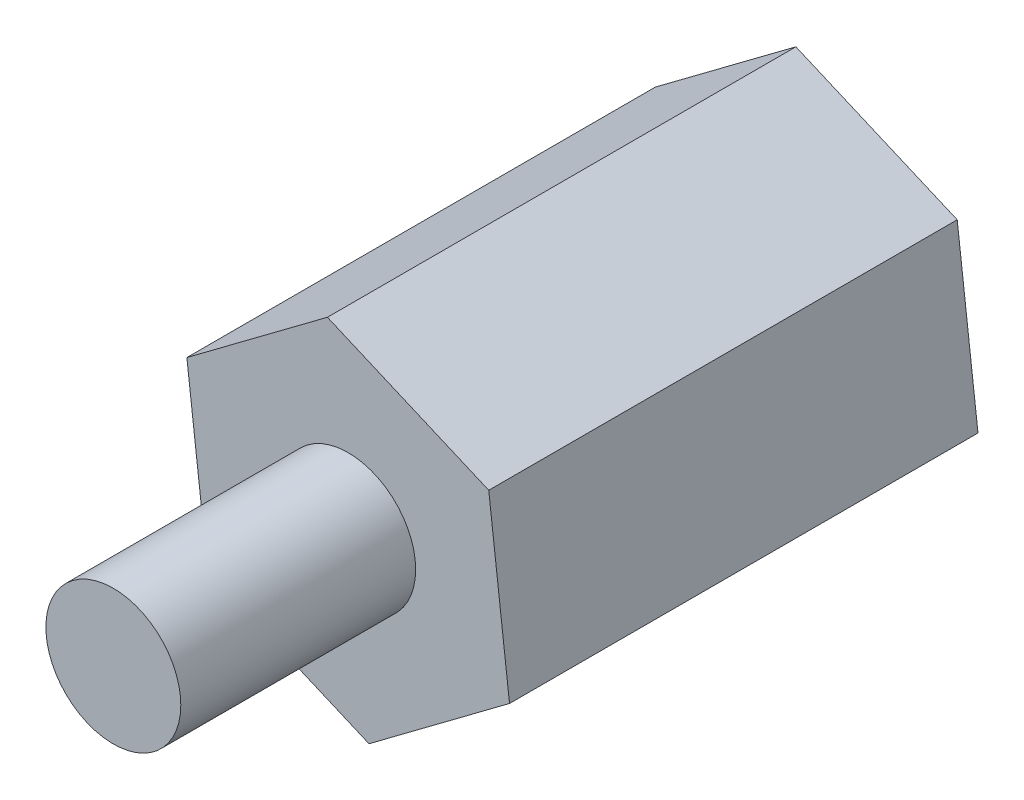
from build123d import *

# Parameters (mm, degrees)
SKETCH7_R           = 1.3716
BOSS_EXTRUDE4_DEPTH = 4.7625
SKETCH8_R           = 1.3716
BOSS_EXTRUDE5_DEPTH = 4.7752


with BuildPart() as part:
    # Sketch7 → Boss-Extrude4 (new, symmetric)
    with BuildSketch(Plane.XY):
        Polygon((-76.439762625, 4.738534743), (-76.86239804, 8.282120356), (-80.142550908, 9.687900156), (-83.000068362, 7.550094344), (-82.577432948, 4.006508731), (-79.297280079, 2.600728931), align=None)
        with Locations((-79.719915494, 6.144314544)):
            Circle(SKETCH7_R, mode=Mode.SUBTRACT)
    extrude(amount=BOSS_EXTRUDE4_DEPTH, both=True)


with BuildPart() as body_2:
    # Sketch8 → Boss-Extrude5 (new body)
    with BuildSketch(Plane.XY.offset(4.7625)):
        with Locations((-79.719915494, 6.144314544)):
            Circle(SKETCH8_R)
    extrude(amount=BOSS_EXTRUDE5_DEPTH)


solid = Compound([part.part, body_2.part])
